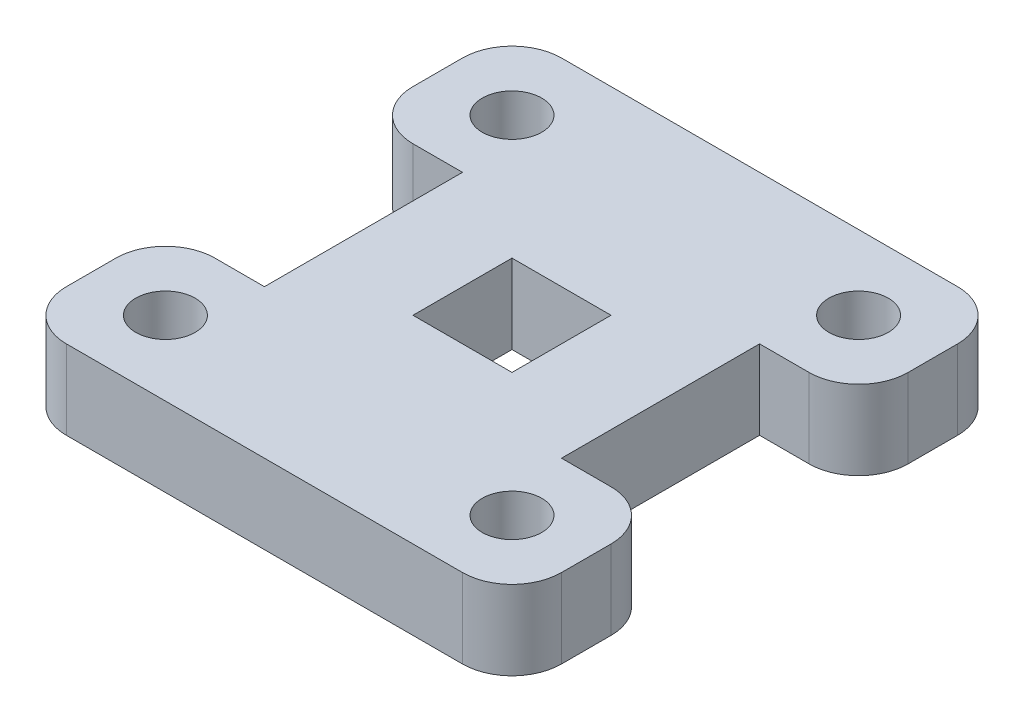
from build123d import *

# Parameters (mm, degrees)
SKETCH1_R           = 6
SKETCH1_W           = 20
SKETCH1_H           = 20
BOSS_EXTRUDE1_DEPTH = 16


with BuildPart() as part:
    # Sketch1 → Boss-Extrude1 (new body)
    with BuildSketch(Plane(origin=(0, 0, 0), x_dir=(1, 0, 0), z_dir=(0, 1, 0))):
        with BuildLine():
            Line((-30, 20), (-30, -20))
            Line((-30, -20), (-40, -20))
            ThreePointArc((-40, -20), (-47.071067812, -22.928932188), (-50, -30))
            Line((-50, -30), (-50, -40))
            ThreePointArc((-50, -40), (-47.071067812, -47.071067812), (-40, -50))
            Line((-40, -50), (40, -50))
            ThreePointArc((40, -50), (47.071067812, -47.071067812), (50, -40))
            Line((50, -40), (50, -30))
            ThreePointArc((50, -30), (47.071067812, -22.928932188), (40, -20))
            Line((40, -20), (30, -20))
            Line((30, -20), (30, 20))
            Line((30, 20), (40, 20))
            ThreePointArc((40, 20), (47.071067812, 22.928932188), (50, 30))
            Line((50, 30), (50, 40))
            ThreePointArc((50, 40), (47.071067812, 47.071067812), (40, 50))
            Line((40, 50), (-40, 50))
            ThreePointArc((-40, 50), (-47.071067812, 47.071067812), (-50, 40))
            Line((-50, 40), (-50, 30))
            ThreePointArc((-50, 30), (-47.071067812, 22.928932188), (-40, 20))
            Line((-40, 20), (-30, 20))
        make_face()
        with Locations((-35, 35)):
            Circle(SKETCH1_R, mode=Mode.SUBTRACT)
        with Locations((35, 35)):
            Circle(SKETCH1_R, mode=Mode.SUBTRACT)
        with Locations((35, -35)):
            Circle(SKETCH1_R, mode=Mode.SUBTRACT)
        with Locations((-35, -35)):
            Circle(SKETCH1_R, mode=Mode.SUBTRACT)
        Rectangle(SKETCH1_W, SKETCH1_H, mode=Mode.SUBTRACT)
    extrude(amount=BOSS_EXTRUDE1_DEPTH)


solid = part.part
